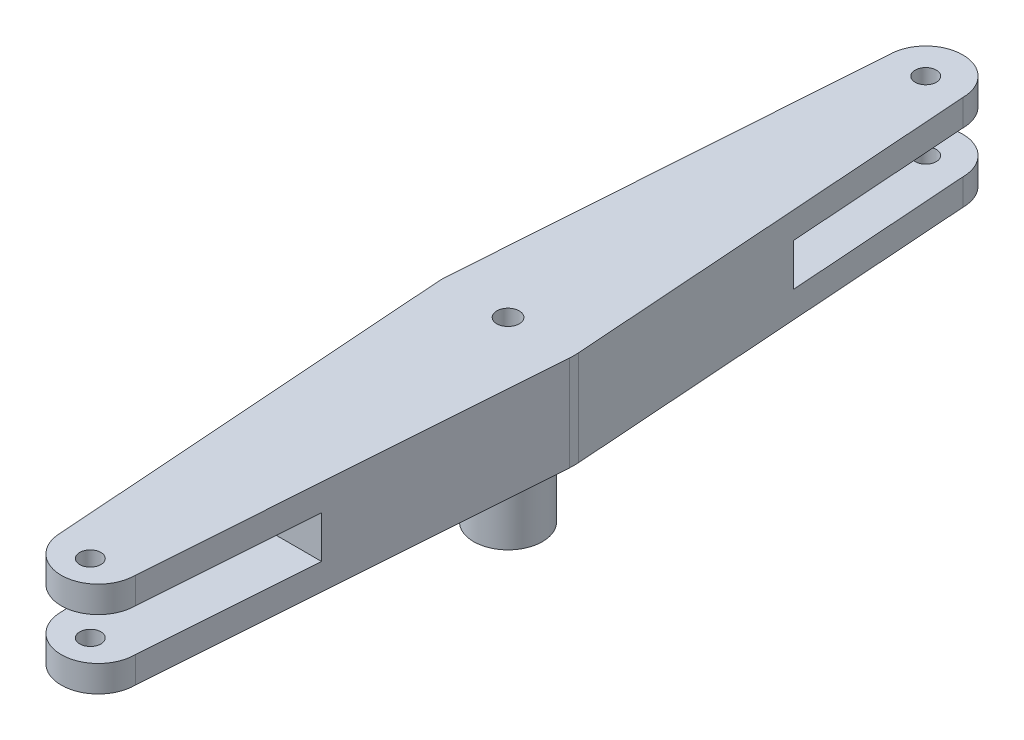
from build123d import *

# Parameters (mm, degrees)
SKETCH1_R           = 2.125
BOSS_EXTRUDE1_DEPTH = 5
SKETCH2_R           = 2
CUT_EXTRUDE1_DEPTH  = 10
SKETCH5_R           = 6.5
BOSS_EXTRUDE2_DEPTH = 15.5
BOSS_EXTRUDE3_DEPTH = 8
SKETCH8_R           = 2
CUT_EXTRUDE2_DEPTH  = 34.5


with BuildPart() as part:
    # Sketch1 → Boss-Extrude1 (new body)
    with BuildSketch(Plane(origin=(0, 0, 0), x_dir=(1, 0, 0), z_dir=(0, 1, 0))):
        with BuildLine():
            Line((-7, 79), (-12.469480556, 0.872957419))
            ThreePointArc((-12.469480556, 0.872957419), (-12.499997094, -0.008523482), (-12.468278459, -0.889961946))
            Line((-12.468278459, -0.889961946), (-7, -77.5))
            ThreePointArc((-7, -77.5), (0, -84.5), (7, -77.5))
            Line((7, -77.5), (12.468278459, -0.889961946))
            ThreePointArc((12.468278459, -0.889961946), (12.499997094, -0.008523482), (12.469480556, 0.872957419))
            Line((12.469480556, 0.872957419), (7, 79))
            ThreePointArc((7, 79), (0, 86), (-7, 79))
        make_face()
        Circle(SKETCH1_R, mode=Mode.SUBTRACT)
    boss_extrude1 = extrude(amount=BOSS_EXTRUDE1_DEPTH)

    # Sketch2 → Cut-Extrude1 (cut)
    with BuildSketch(Plane(origin=(0, 5, 0), x_dir=(1, 0, 0), z_dir=(0, 1, 0))):
        with Locations((0, 79)):
            Circle(SKETCH2_R)
        with Locations((0, -79)):
            Circle(SKETCH2_R)
    cut_extrude1 = extrude(amount=-CUT_EXTRUDE1_DEPTH, mode=Mode.SUBTRACT)

    # Sketch5 → Boss-Extrude2 (add)
    with BuildSketch(Plane.XZ):
        Circle(SKETCH5_R)
    extrude(amount=BOSS_EXTRUDE2_DEPTH)

    # Sketch6 → Boss-Extrude3 (add)
    with BuildSketch(Plane(origin=(0, 5, 0), x_dir=(1, 0, 0), z_dir=(0, 1, 0))):
        with BuildLine():
            Line((-9.4069118, 44.619239575), (9.4069118, 44.619239575))
            Line((9.4069118, 44.619239575), (12.469480556, 0.872957419))
            ThreePointArc((12.469480556, 0.872957419), (12.499997094, -0.008523482), (12.468278459, -0.889961946))
            Line((12.468278459, -0.889961946), (9.346965992, -44.619239575))
            Line((9.346965992, -44.619239575), (-9.346965992, -44.619239575))
            Line((-9.346965992, -44.619239575), (-12.468278459, -0.889961946))
            ThreePointArc((-12.468278459, -0.889961946), (-12.499997094, -0.008523482), (-12.469480556, 0.872957419))
            Line((-12.469480556, 0.872957419), (-9.4069118, 44.619239575))
        make_face()
    extrude(amount=BOSS_EXTRUDE3_DEPTH)

    # Mirror1: Boss-Extrude1, Cut-Extrude1 across plane
    add(boss_extrude1.mirror(Plane.ZX.offset(9)))
    add(cut_extrude1.mirror(Plane.ZX.offset(9)), mode=Mode.SUBTRACT)

    # Sketch8 → Cut-Extrude2 (cut, through all)
    with BuildSketch(Plane.XZ.offset(15.5)):
        Circle(SKETCH8_R)
    extrude(amount=-CUT_EXTRUDE2_DEPTH, mode=Mode.SUBTRACT)


solid = part.part
